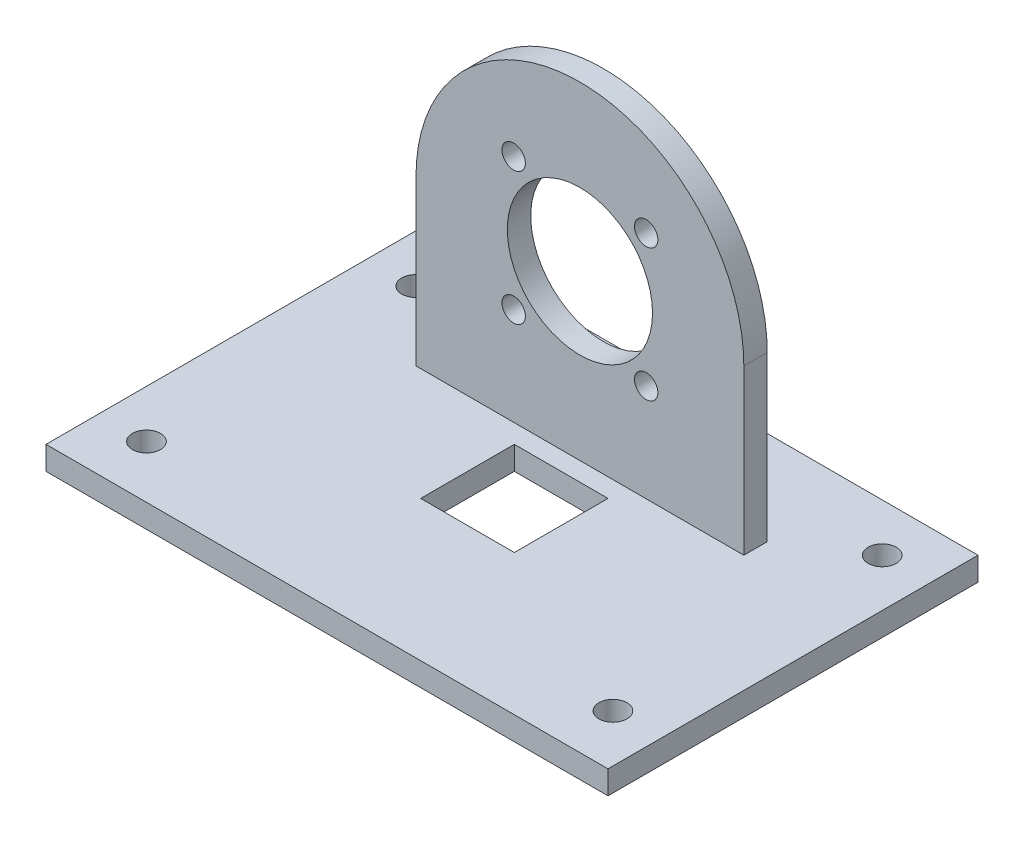
from build123d import *

# Parameters (mm, degrees)
SKETCH1_R           = 3
BOSS_EXTRUDE1_DEPTH = 5
SKETCH2_W           = 70
SKETCH2_H           = 5
BOSS_EXTRUDE2_DEPTH = 70
CUT_EXTRUDE1_DEPTH  = 20
SKETCH4_R           = 15.5
CUT_EXTRUDE2_DEPTH  = 10
CUT_EXTRUDE6_REACH  = 77
SKETCH8_W           = 20
SKETCH8_H           = 20
SKETCH9_W           = 40
SKETCH9_H           = 5
CUT_EXTRUDE7_DEPTH  = 30
SKETCH10_R          = 2.5
CUT_EXTRUDE8_DEPTH  = 5


with BuildPart() as part:
    # Sketch1 → Boss-Extrude1 (new body)
    with BuildSketch(Plane(origin=(0, 0, 0), x_dir=(1, 0, 0), z_dir=(0, 1, 0))):
        Polygon((-35, -40), (-20, -40), (-20, -70), (20, -70), (20, -40), (35, -40), (60, -40), (60, 39), (-60, 39), (-60, -40), align=None)
        with Locations((49.796460718, 28.75)):
            Circle(SKETCH1_R, mode=Mode.SUBTRACT)
        with Locations((49.796460718, -28.75)):
            Circle(SKETCH1_R, mode=Mode.SUBTRACT)
        with Locations((0, -57.5)):
            Circle(SKETCH1_R, mode=Mode.SUBTRACT)
        with Locations((-49.796460718, -28.75)):
            Circle(SKETCH1_R, mode=Mode.SUBTRACT)
        with Locations((-49.796460718, 28.75)):
            Circle(SKETCH1_R, mode=Mode.SUBTRACT)
    extrude(amount=BOSS_EXTRUDE1_DEPTH)

    # Sketch2 → Boss-Extrude2 (add)
    with BuildSketch(Plane(origin=(0, 5, 0), x_dir=(1, 0, 0), z_dir=(0, 1, 0))):
        with Locations((0, 16.5)):
            Rectangle(SKETCH2_W, SKETCH2_H)
    extrude(amount=BOSS_EXTRUDE2_DEPTH)

    # Sketch3 → Cut-Extrude1 (cut)
    with BuildSketch(Plane(origin=(0, 0, -19), x_dir=(-1, 0, 0), z_dir=(0, 0, -1))):
        with BuildLine():
            ThreePointArc((-35, 40.000002437), (-24.74873648, 64.748738203), (0, 75))
            Line((0, 75), (-35, 75))
            Line((-35, 75), (-35, 40.000002437))
        make_face()
        with BuildLine():
            Line((35, 40.000002339), (35, 75))
            Line((35, 75), (0, 75))
            ThreePointArc((0, 75), (24.748736514, 64.748738169), (35, 40.000002339))
        make_face()
    extrude(amount=-CUT_EXTRUDE1_DEPTH, mode=Mode.SUBTRACT)

    # Sketch4 → Cut-Extrude2 (cut)
    with BuildSketch(Plane.XY.offset(-14)):
        with Locations((0, 40)):
            Circle(SKETCH4_R)
    extrude(amount=-CUT_EXTRUDE2_DEPTH, mode=Mode.SUBTRACT)

    # Sketch8 → Cut-Extrude6 (cut, up to next)
    with BuildSketch(Plane.XZ, mode=Mode.PRIVATE) as cut_extrude6_sk1:
        Rectangle(SKETCH8_W, SKETCH8_H)
    cut_extrude6_tool1 = extrude(cut_extrude6_sk1.sketch, amount=-CUT_EXTRUDE6_REACH, mode=Mode.PRIVATE) & part.part
    add(cut_extrude6_tool1.solids().sort_by_distance((0, 0, 0))[0], mode=Mode.SUBTRACT)

    # Sketch9 → Cut-Extrude7 (cut)
    with BuildSketch(Plane.XY.offset(70)):
        with Locations((0, 2.5)):
            Rectangle(SKETCH9_W, SKETCH9_H)
    extrude(amount=-CUT_EXTRUDE7_DEPTH, mode=Mode.SUBTRACT)

    # Sketch10 → Cut-Extrude8 (cut)
    with BuildSketch(Plane(origin=(0, 0, -19), x_dir=(-1, 0, 0), z_dir=(0, 0, -1))):
        with Locations((14.142135624, 54.142135624)):
            Circle(SKETCH10_R)
        with Locations((14.142135624, 25.857864376)):
            Circle(SKETCH10_R)
        with Locations((-14.142135624, 25.857864376)):
            Circle(SKETCH10_R)
        with Locations((-14.142135624, 54.142135624)):
            Circle(SKETCH10_R)
    extrude(amount=-CUT_EXTRUDE8_DEPTH, mode=Mode.SUBTRACT)


solid = part.part
